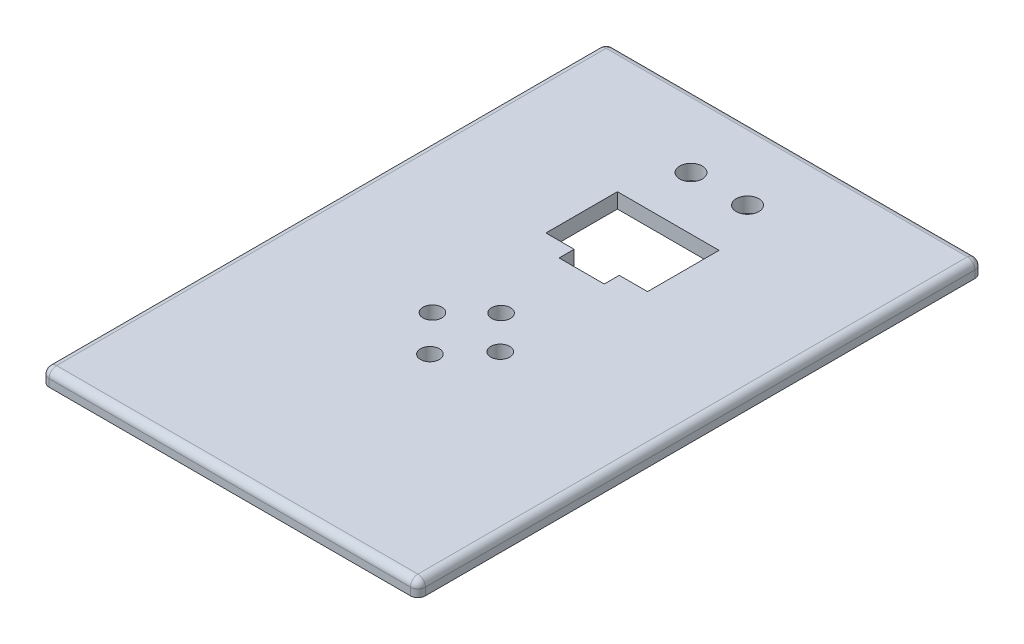
from build123d import *

# Parameters (mm, degrees)
SKETCH1_W           = 100
SKETCH1_H           = 150
BOSS_EXTRUDE1_DEPTH = 4
CUT_EXTRUDE1_DEPTH  = 4
SKETCH2_4_W         = 12
SKETCH2_4_H         = 4
CUT_EXTRUDE2_DEPTH  = 4
SKETCH3_R           = 2.5
CUT_EXTRUDE3_DEPTH  = 4
SKETCH4_R           = 3
CUT_EXTRUDE4_DEPTH  = 4
FILLET1_R           = 2


with BuildPart() as part:
    # Sketch1 → Boss-Extrude1 (new body)
    with BuildSketch(Plane(origin=(0, 0, 0), x_dir=(1, 0, 0), z_dir=(0, 1, 0))):
        with Locations((50, 75)):
            Rectangle(SKETCH1_W, SKETCH1_H)
    extrude(amount=BOSS_EXTRUDE1_DEPTH)

    # Sketch2 → Cut-Extrude1 (cut)
    with BuildSketch(Plane(origin=(0, 4, 0), x_dir=(1, 0, 0), z_dir=(0, 1, 0))):
        Polygon((63.5, 116.508398101), (36.5, 116.508398101), (36.5, 97.508398101), (44, 97.508398101), (56, 97.508398101), (63.5, 97.508398101), align=None)
    extrude(amount=-CUT_EXTRUDE1_DEPTH, mode=Mode.SUBTRACT)

    # Sketch2_4 → Cut-Extrude2 (cut)
    with BuildSketch(Plane(origin=(0, 4, 0), x_dir=(1, 0, 0), z_dir=(0, 1, 0))):
        with Locations((50, 95.508398101)):
            Rectangle(SKETCH2_4_W, SKETCH2_4_H)
    extrude(amount=-CUT_EXTRUDE2_DEPTH, mode=Mode.SUBTRACT)

    # Sketch3 → Cut-Extrude3 (cut)
    with BuildSketch(Plane(origin=(0, 4, 0), x_dir=(1, 0, 0), z_dir=(0, 1, 0))):
        with Locations((48.975949338, 73.129510144)):
            Circle(SKETCH3_R)
        with Locations((48.975949338, 54.212155816)):
            Circle(SKETCH3_R)
        with Locations((57.774718793, 64.110771453)):
            Circle(SKETCH3_R)
        with Locations((39.737241411, 64.110771453)):
            Circle(SKETCH3_R)
    extrude(amount=-CUT_EXTRUDE3_DEPTH, mode=Mode.SUBTRACT)

    # Sketch4 → Cut-Extrude4 (cut)
    with BuildSketch(Plane(origin=(0, 4, 0), x_dir=(1, 0, 0), z_dir=(0, 1, 0))):
        with Locations((56.881630687, 130.696209526)):
            Circle(SKETCH4_R)
        with Locations((41.869015261, 130.696209526)):
            Circle(SKETCH4_R)
    extrude(amount=-CUT_EXTRUDE4_DEPTH, mode=Mode.SUBTRACT)

    # Fillet1
    fillet1_edges = [part.edges().sort_by_distance(p)[0] for p in [
        (0, 2, 0),
        (50, 4, 0),
        (100, 2, 0),
        (100, 4, -75),
        (100, 2, -150),
        (0, 2, -150),
        (0, 4, -75),
        (50, 4, -150),
    ]]
    fillet(fillet1_edges, radius=FILLET1_R)


solid = part.part
